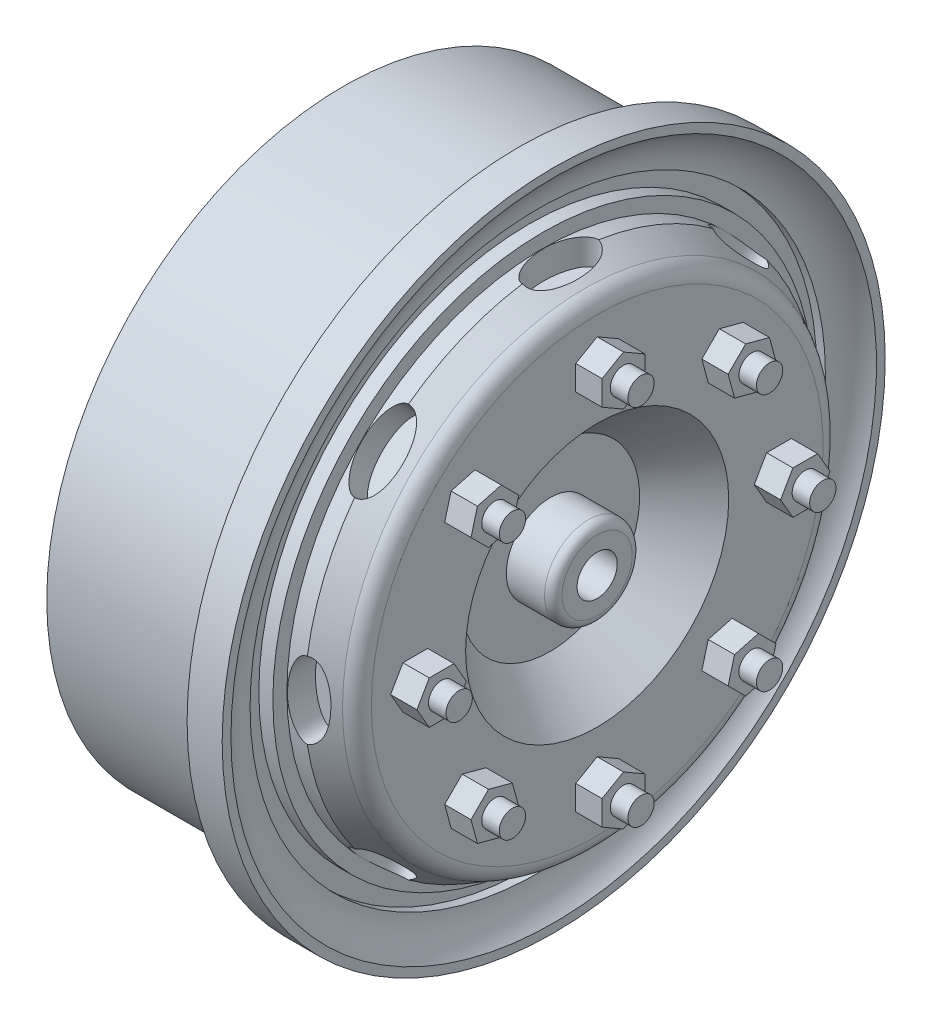
from build123d import *

# Parameters (mm, degrees)
SKETCH2_R           = 2.5
BOSS_EXTRUDE1_DEPTH = 2.676537
FILLET2_R           = 0.5
SKETCH3_R           = 1.144876819
CUT_EXTRUDE1_DEPTH  = 2
SKETCH4_RX          = 2.170606372
SKETCH4_RY          = 0.972383775
CUT_EXTRUDE2_DEPTH  = 2
CIRPATTERN1_COUNT   = 8
BOSS_EXTRUDE2_DEPTH = 1.5
SKETCH6_R           = 0.75
BOSS_EXTRUDE3_DEPTH = 1


with BuildPart() as part:
    # Sketch1 → Revolve1 (revolve)
    with BuildSketch(Plane(origin=(0, 0, 0), x_dir=(1, 0, 0), z_dir=(0, 1, 0))):
        with BuildLine():
            Line((-6, 16.9), (4, 16.9))
            Line((4, 16.9), (4, 18.9))
            Line((4, 18.9), (6, 18.9))
            Line((6, 18.9), (6, 18.4))
            ThreePointArc((6, 18.4), (5.328475711, 17.498565431), (5.09039348, 16.4))
            Line((5.09039348, 16.4), (4.59039348, 16.4))
            Line((4.59039348, 16.4), (4.59039348, 15.4))
            Line((4.59039348, 15.4), (5.39039348, 15.4))
            Line((5.39039348, 15.4), (5.39039348, 14.6))
            Line((5.39039348, 14.6), (6.39039348, 14.6))
            Line((6.39039348, 14.6), (7.784787805, 13.824146889))
            ThreePointArc((7.784787805, 13.824146889), (8.285317439, 13.460952842), (8.476537355, 12.872841649))
            Line((8.476537355, 12.872841649), (8.476537355, 7.5))
            Line((8.476537355, 7.5), (5.8, 5.1))
            Line((5.8, 5.1), (5.8, 0))
            Line((5.8, 0), (3.617701759, 0))
            Line((3.617701759, 0), (3.617701759, 10.5))
            Line((3.617701759, 10.5), (-6, 10.5))
            Line((-6, 10.5), (-6, 16.9))
        make_face()
    revolve(axis=Axis((-25, 0, 0), (1, 0, 0)))

    # Sketch2 → Boss-Extrude1 (add)
    with BuildSketch(Plane(origin=(5.8, 0, 0), x_dir=(0, 0, -1), z_dir=(1, 0, 0))):
        Circle(SKETCH2_R)
    extrude(amount=BOSS_EXTRUDE1_DEPTH)

    # Fillet2
    fillet2_edges = [part.edges().sort_by_distance(p)[0] for p in [
        (8.476537, 0, 2.5),
    ]]
    fillet(fillet2_edges, radius=FILLET2_R)

    # Sketch3 → Cut-Extrude1 (cut)
    with BuildSketch(Plane(origin=(8.476537355, 0, 0), x_dir=(0, 0, -1), z_dir=(1, 0, 0))):
        Circle(SKETCH3_R)
    extrude(amount=-CUT_EXTRUDE1_DEPTH, mode=Mode.SUBTRACT)

    # Sketch4 → Cut-Extrude2 (cut)
    with BuildSketch(Plane(origin=(0, 15, 0), x_dir=(1, 0, 0), z_dir=(0, 1, 0))):
        with Locations(Location((6.39039348, 0), (0, 0, -90))):
            Ellipse(SKETCH4_RX, SKETCH4_RY)
    cut_extrude2 = extrude(amount=-CUT_EXTRUDE2_DEPTH, mode=Mode.SUBTRACT)

    # CirPattern1: Cut-Extrude2 ×8 about axis
    cirpattern1_axis = Axis((6.39039348, 0, 0), (-1, 0, 0))
    for i in range(1, CIRPATTERN1_COUNT):
        add(cut_extrude2.rotate(cirpattern1_axis, i * 360 / CIRPATTERN1_COUNT), mode=Mode.SUBTRACT)

    # Sketch5 → Boss-Extrude2 (add)
    with BuildSketch(Plane(origin=(8.476537355, 0, 0), x_dir=(0, 0, -1), z_dir=(1, 0, 0))):
        Polygon((6.332599903, 6.332599903), (7.694361829, 5.967716895), (8.691240747, 6.964595812), (8.326357739, 8.326357739), (6.964595812, 8.691240747), (5.967716895, 7.694361829), align=None)
        Polygon((0, 8.955648668), (1.220922342, 9.660548511), (1.220922342, 11.070348197), (0, 11.775248039), (-1.220922342, 11.070348197), (-1.220922342, 9.660548511), align=None)
        Polygon((8.955648668, 0), (9.660548511, -1.220922342), (11.070348197, -1.220922342), (11.775248039, 0), (11.070348197, 1.220922342), (9.660548511, 1.220922342), align=None)
        Polygon((6.332599903, -6.332599903), (5.967716895, -7.694361829), (6.964595812, -8.691240747), (8.326357739, -8.326357739), (8.691240747, -6.964595812), (7.694361829, -5.967716895), align=None)
        Polygon((0, -8.955648668), (-1.220922342, -9.660548511), (-1.220922342, -11.070348197), (0, -11.775248039), (1.220922342, -11.070348197), (1.220922342, -9.660548511), align=None)
        Polygon((-6.332599903, -6.332599903), (-7.694361829, -5.967716895), (-8.691240747, -6.964595812), (-8.326357739, -8.326357739), (-6.964595812, -8.691240747), (-5.967716895, -7.694361829), align=None)
        Polygon((-8.955648668, 0), (-9.660548511, 1.220922342), (-11.070348197, 1.220922342), (-11.775248039, 0), (-11.070348197, -1.220922342), (-9.660548511, -1.220922342), align=None)
        Polygon((-6.332599903, 6.332599903), (-5.967716895, 7.694361829), (-6.964595812, 8.691240747), (-8.326357739, 8.326357739), (-8.691240747, 6.964595812), (-7.694361829, 5.967716895), align=None)
    extrude(amount=BOSS_EXTRUDE2_DEPTH)

    # Sketch6 → Boss-Extrude3 (add)
    with BuildSketch(Plane(origin=(9.976537355, 0, 0), x_dir=(0, 0, -1), z_dir=(1, 0, 0))):
        with Locations((0, -10.365448354)):
            Circle(SKETCH6_R)
        with Locations((-7.329478821, -7.329478821)):
            Circle(SKETCH6_R)
        with Locations((-10.365448354, 0)):
            Circle(SKETCH6_R)
        with Locations((-7.329478821, 7.329478821)):
            Circle(SKETCH6_R)
        with Locations((0, 10.365448354)):
            Circle(SKETCH6_R)
        with Locations((7.329478821, 7.329478821)):
            Circle(SKETCH6_R)
        with Locations((10.365448354, 0)):
            Circle(SKETCH6_R)
        with Locations((7.329478821, -7.329478821)):
            Circle(SKETCH6_R)
    extrude(amount=BOSS_EXTRUDE3_DEPTH)


solid = part.part
